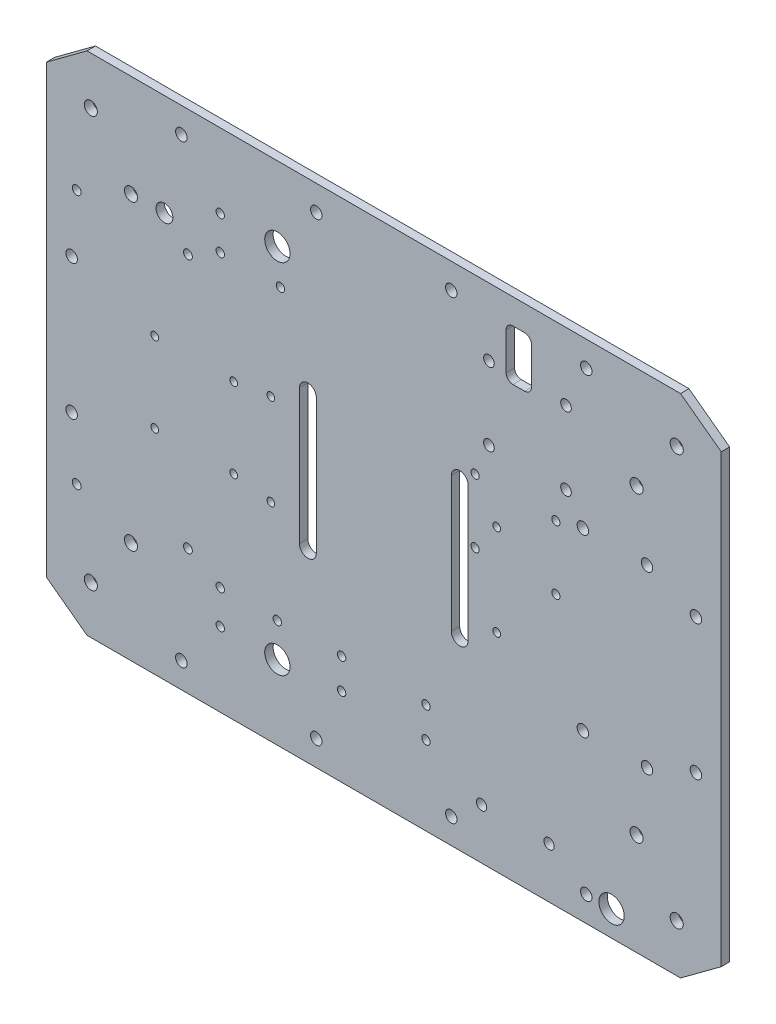
from build123d import *

# Parameters (mm, degrees)
SKETCH1_R                = 2.4638
BOSS_EXTRUDE1_DEPTH      = 3.175
SKETCH5_R                = 3.175
SKETCH5_R_2              = 1.651
SKETCH5_R_3              = 1.4478
CUT_EXTRUDE2_DEPTH       = 4.175
SKETCH6_R                = 2.159
CUT_EXTRUDE3_DEPTH       = 4.175
SKETCH5_3_R              = 1.45415
CUT_EXTRUDE4_DEPTH       = 4.175
SKETCH5_4_R              = 1.5875
SKETCH5_4_R_2            = 4.7625
CUT_EXTRUDE5_DEPTH       = 4.175
SKETCH5_5_R              = 1.5875
CUT_EXTRUDE6_DEPTH       = 2.54
SKETCH5_6_R              = 1.5875
CUT_EXTRUDE7_DEPTH       = 4.175
SKETCH5_7_R              = 1.5875
SKETCH5_7_W              = 9.525
SKETCH5_7_H              = 19.05
CUT_EXTRUDE8_DEPTH       = 7.62
CUT_EXTRUDE8_DEPTH_BACK  = 2.54
SKETCH5_9_R              = 1.5875
CUT_EXTRUDE9_DEPTH       = 4.175
SKETCH5_15_R             = 2.159
SKETCH5_15_W             = 9.525
SKETCH5_15_H             = 19.05
CUT_EXTRUDE17_DEPTH      = 1
CUT_EXTRUDE17_DEPTH_BACK = 4.175
FILLET1_R                = 2.54
FILLET2_R                = 2.54
SKETCH2_R                = 1.9431
CUT_EXTRUDE20_DEPTH      = 4.175
FILLET3_R                = 2.54
FILLET4_R                = 2.54
SKETCH9_R                = 1.55
SKETCH9_R_2              = 2
CUT_EXTRUDE18_DEPTH      = 4.175
SKETCH3_R                = 1.5875
CUT_EXTRUDE19_DEPTH      = 976.122


with BuildPart() as part:
    # Sketch1 → Boss-Extrude1 (new body)
    with BuildSketch(Plane.XY):
        Polygon((-111.686526805, -95.25), (-127, -83.918625912), (-127, 83.918625912), (-111.686526805, 95.25), (111.686526805, 95.25), (127, 83.918625912), (127, -83.918625912), (111.686526805, -95.25), align=None)
        with Locations((-95.147512794, 56.885632681)):
            Circle(SKETCH1_R, mode=Mode.SUBTRACT)
        with Locations((-110.256011578, 77.303596941)):
            Circle(SKETCH1_R, mode=Mode.SUBTRACT)
        with Locations((110.256011578, 77.303596941)):
            Circle(SKETCH1_R, mode=Mode.SUBTRACT)
        with Locations((95.147512794, 56.885632681)):
            Circle(SKETCH1_R, mode=Mode.SUBTRACT)
        with Locations((-110.256011578, -77.303596941)):
            Circle(SKETCH1_R, mode=Mode.SUBTRACT)
        with Locations((-95.147512794, -56.885632681)):
            Circle(SKETCH1_R, mode=Mode.SUBTRACT)
        with Locations((110.256011578, -77.303596941)):
            Circle(SKETCH1_R, mode=Mode.SUBTRACT)
        with Locations((95.147512794, -56.885632681)):
            Circle(SKETCH1_R, mode=Mode.SUBTRACT)
    extrude(amount=BOSS_EXTRUDE1_DEPTH)

    # Sketch5 → Cut-Extrude2 (cut, through all)
    with BuildSketch(Plane(origin=(0, 0, 0), x_dir=(-1, 0, 0), z_dir=(0, 0, -1))):
        with BuildLine():
            Line((-25.4, -25.4), (-25.4, 25.4))
            ThreePointArc((-25.4, 25.4), (-28.575, 28.575), (-31.75, 25.4))
            Line((-31.75, 25.4), (-31.75, -25.4))
            ThreePointArc((-31.75, -25.4), (-28.575, -28.575), (-25.4, -25.4))
        make_face()
        with BuildLine():
            ThreePointArc((31.75, 25.4), (28.575, 28.575), (25.4, 25.4))
            Line((25.4, 25.4), (25.4, -25.4))
            ThreePointArc((25.4, -25.4), (28.575, -28.575), (31.75, -25.4))
            Line((31.75, -25.4), (31.75, 25.4))
        make_face()
        with Locations((82.55, 56.995822)):
            Circle(SKETCH5_R)
        with Locations((73.703688, 47.915322)):
            Circle(SKETCH5_R_2)
        with Locations((115.57, 47.915322)):
            Circle(SKETCH5_R_2)
        with Locations((73.703688, -47.915322)):
            Circle(SKETCH5_R_2)
        with Locations((115.57, -47.915322)):
            Circle(SKETCH5_R_2)
        with Locations((56.479426463, 15.03413)):
            Circle(SKETCH5_R_3)
        with Locations((56.479426463, -15.03413)):
            Circle(SKETCH5_R_3)
        with Locations((86.197426463, -15.03413)):
            Circle(SKETCH5_R_3)
        with Locations((86.197426463, 15.03413)):
            Circle(SKETCH5_R_3)
    extrude(amount=-CUT_EXTRUDE2_DEPTH, mode=Mode.SUBTRACT)

    # Sketch6 → Cut-Extrude3 (cut, through all)
    with BuildSketch(Plane(origin=(0, 0, 0), x_dir=(-1, 0, 0), z_dir=(0, 0, -1))):
        with Locations((-76.2, -85.725)):
            Circle(SKETCH6_R)
        with Locations((-25.4, -85.725)):
            Circle(SKETCH6_R)
        with Locations((25.4, -85.725)):
            Circle(SKETCH6_R)
        with Locations((76.2, -85.725)):
            Circle(SKETCH6_R)
        with Locations((76.2, 85.725)):
            Circle(SKETCH6_R)
        with Locations((25.4, 85.725)):
            Circle(SKETCH6_R)
        with Locations((-25.4, 85.725)):
            Circle(SKETCH6_R)
        with Locations((-76.2, 85.725)):
            Circle(SKETCH6_R)
        with Locations((117.475, -25.4)):
            Circle(SKETCH6_R)
        with Locations((117.475, 25.4)):
            Circle(SKETCH6_R)
        with Locations((-117.475, 25.4)):
            Circle(SKETCH6_R)
        with Locations((-117.475, -25.4)):
            Circle(SKETCH6_R)
    extrude(amount=-CUT_EXTRUDE3_DEPTH, mode=Mode.SUBTRACT)

    # Sketch5_3 → Cut-Extrude4 (cut, through all)
    with BuildSketch(Plane(origin=(0, 0, 0), x_dir=(-1, 0, 0), z_dir=(0, 0, -1))):
        with Locations((-42.5, 17.2)):
            Circle(SKETCH5_3_R)
        with Locations((-42.5, -17.2)):
            Circle(SKETCH5_3_R)
        with Locations((42.5, -17.2)):
            Circle(SKETCH5_3_R)
        with Locations((42.5, 17.2)):
            Circle(SKETCH5_3_R)
    extrude(amount=-CUT_EXTRUDE4_DEPTH, mode=Mode.SUBTRACT)

    # Sketch5_4 → Cut-Extrude5 (cut, through all)
    with BuildSketch(Plane(origin=(0, 0, 0), x_dir=(-1, 0, 0), z_dir=(0, 0, -1))):
        with Locations((61.544630637, -54.61)):
            Circle(SKETCH5_4_R)
        with Locations((61.544630637, -67.31)):
            Circle(SKETCH5_4_R)
        with Locations((-85.725, -85.725)):
            Circle(SKETCH5_4_R_2)
        with Locations((61.544630637, 54.61)):
            Circle(SKETCH5_4_R)
        with Locations((40.055369363, -67.31)):
            Circle(SKETCH5_4_R_2)
        with Locations((61.544630637, 67.31)):
            Circle(SKETCH5_4_R)
        with Locations((40.055369363, 67.31)):
            Circle(SKETCH5_4_R_2)
    extrude(amount=-CUT_EXTRUDE5_DEPTH, mode=Mode.SUBTRACT)

    # Sketch5_5 → Cut-Extrude6 (cut)
    with BuildSketch(Plane(origin=(0, 0, 0), x_dir=(-1, 0, 0), z_dir=(0, 0, -1))):
        with Locations((38.886108088, 54.61)):
            Circle(SKETCH5_5_R)
    extrude(amount=-CUT_EXTRUDE6_DEPTH, mode=Mode.SUBTRACT)

    # Sketch5_6 → Cut-Extrude7 (cut, through all)
    with BuildSketch(Plane(origin=(0, 0, 0), x_dir=(-1, 0, 0), z_dir=(0, 0, -1))):
        with Locations((38.886108088, 54.61)):
            Circle(SKETCH5_6_R)
    extrude(amount=-CUT_EXTRUDE7_DEPTH, mode=Mode.SUBTRACT)

    # Sketch5_7 → Cut-Extrude8 (cut, two sides)
    with BuildSketch(Plane(origin=(0, 0, 0), x_dir=(-1, 0, 0), z_dir=(0, 0, -1))) as cut_extrude8_sk:
        with Locations((40.055369363, -54.61)):
            Circle(SKETCH5_7_R)
        with Locations((-50.8, 76.2)):
            Rectangle(SKETCH5_7_W, SKETCH5_7_H)
    extrude(amount=CUT_EXTRUDE8_DEPTH, mode=Mode.SUBTRACT)
    extrude(cut_extrude8_sk.sketch, amount=-CUT_EXTRUDE8_DEPTH_BACK, mode=Mode.SUBTRACT)

    # Sketch5_9 → Cut-Extrude9 (cut, through all)
    with BuildSketch(Plane(origin=(0, 0, 0), x_dir=(-1, 0, 0), z_dir=(0, 0, -1))):
        with Locations((40.055369363, -54.61)):
            Circle(SKETCH5_9_R)
    extrude(amount=-CUT_EXTRUDE9_DEPTH, mode=Mode.SUBTRACT)

    # Sketch5_15 → Cut-Extrude17 (cut, two sides)
    with BuildSketch(Plane(origin=(0, 0, 0), x_dir=(-1, 0, 0), z_dir=(0, 0, -1))) as cut_extrude17_sk:
        with Locations((-74.93, -33.02)):
            Circle(SKETCH5_15_R)
        with Locations((-99.06, -33.02)):
            Circle(SKETCH5_15_R)
        with Locations((-99.06, 33.02)):
            Circle(SKETCH5_15_R)
        with Locations((-74.93, 33.02)):
            Circle(SKETCH5_15_R)
        with Locations((-50.8, 76.2)):
            Rectangle(SKETCH5_15_W, SKETCH5_15_H)
    extrude(amount=CUT_EXTRUDE17_DEPTH, mode=Mode.SUBTRACT)
    extrude(cut_extrude17_sk.sketch, amount=-CUT_EXTRUDE17_DEPTH_BACK, mode=Mode.SUBTRACT)

    # Fillet1
    fillet1_edges = [part.edges().sort_by_distance(p)[0] for p in [
        (55.5625, 85.725, 1.5875),
    ]]
    fillet(fillet1_edges, radius=FILLET1_R)

    # Fillet2
    fillet2_edges = [part.edges().sort_by_distance(p)[0] for p in [
        (46.0375, 85.725, 1.5875),
    ]]
    fillet(fillet2_edges, radius=FILLET2_R)

    # Sketch2 → Cut-Extrude20 (cut, through all)
    with BuildSketch(Plane.XY.offset(3.175)):
        with Locations((62.199353496, -76.2)):
            Circle(SKETCH2_R)
        with Locations((36.799353496, -76.2)):
            Circle(SKETCH2_R)
    extrude(amount=-CUT_EXTRUDE20_DEPTH, mode=Mode.SUBTRACT)

    # Fillet3
    fillet3_edges = [part.edges().sort_by_distance(p)[0] for p in [
        (46.0375, 66.675, 1.5875),
    ]]
    fillet(fillet3_edges, radius=FILLET3_R)

    # Fillet4
    fillet4_edges = [part.edges().sort_by_distance(p)[0] for p in [
        (55.5625, 66.675, 1.5875),
    ]]
    fillet(fillet4_edges, radius=FILLET4_R)

    # Sketch9 → Cut-Extrude18 (cut, through all)
    with BuildSketch(Plane.XY.offset(3.175)):
        with Locations((34.370000094, 30.350000006)):
            Circle(SKETCH9_R)
        with Locations((64.77, 30.350000006)):
            Circle(SKETCH9_R)
        with Locations((64.77, 6.35)):
            Circle(SKETCH9_R)
        with Locations((34.370000094, 6.35)):
            Circle(SKETCH9_R)
        with Locations((68.58, 69.85)):
            Circle(SKETCH9_R_2)
        with Locations((39.58, 69.85)):
            Circle(SKETCH9_R_2)
        with Locations((39.58, 42.35)):
            Circle(SKETCH9_R_2)
        with Locations((68.58, 42.35)):
            Circle(SKETCH9_R_2)
    extrude(amount=-CUT_EXTRUDE18_DEPTH, mode=Mode.SUBTRACT)

    # Sketch3 → Cut-Extrude19 (cut)
    with BuildSketch(Plane.XY.offset(3.175)):
        with Locations((-15.875, -65.560310834)):
            Circle(SKETCH3_R)
        with Locations((15.875, -65.560310834)):
            Circle(SKETCH3_R)
        with Locations((-15.875, -54.130310834)):
            Circle(SKETCH3_R)
        with Locations((15.875, -54.130310834)):
            Circle(SKETCH3_R)
    extrude(amount=-CUT_EXTRUDE19_DEPTH, mode=Mode.SUBTRACT)


solid = part.part
